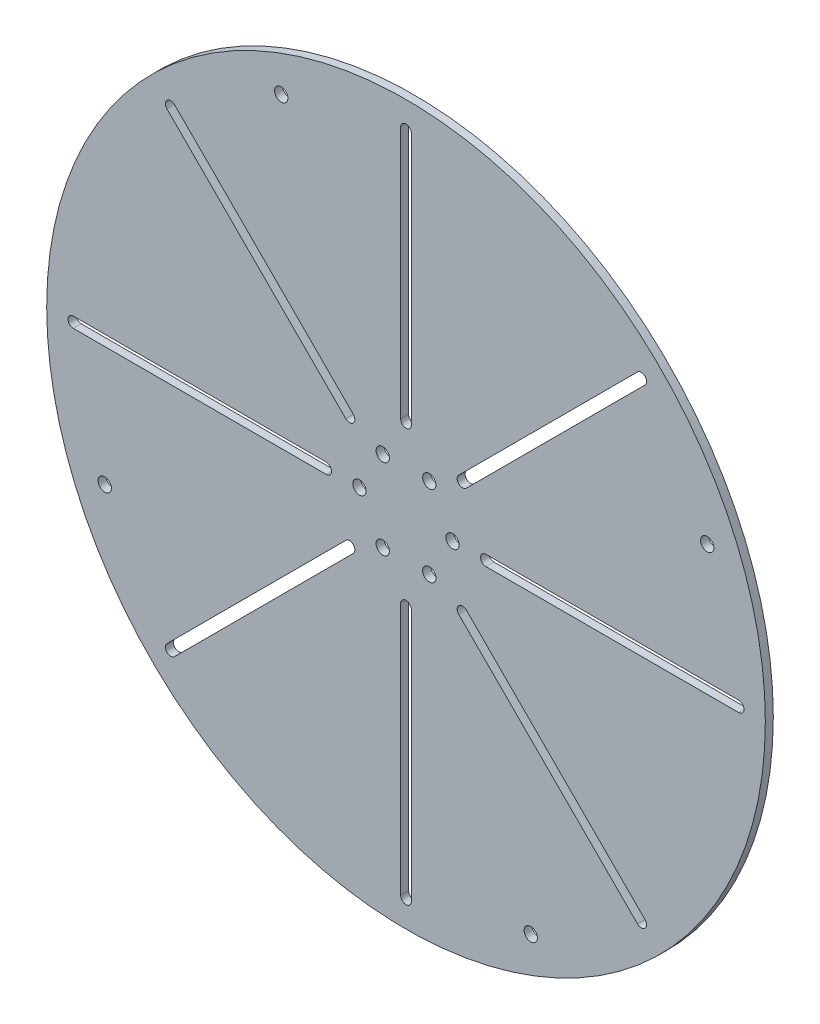
from build123d import *

# Parameters (mm, degrees)
SKETCH1_R           = 135
SKETCH1_R_2         = 2.5
BOSS_EXTRUDE1_DEPTH = 3


with BuildPart() as part:
    # Sketch1 → Boss-Extrude1 (new body)
    with BuildSketch(Plane.XY):
        Circle(SKETCH1_R)
        with Locations((-17.5, 0)):
            Circle(SKETCH1_R_2, mode=Mode.SUBTRACT)
        with Locations((-46.878720465, 113.175242733)):
            Circle(SKETCH1_R_2, mode=Mode.SUBTRACT)
        with Locations((113.175242733, 46.878720465)):
            Circle(SKETCH1_R_2, mode=Mode.SUBTRACT)
        with Locations((46.878720465, -113.175242733)):
            Circle(SKETCH1_R_2, mode=Mode.SUBTRACT)
        with Locations((-8.75, 15.155444566)):
            Circle(SKETCH1_R_2, mode=Mode.SUBTRACT)
        with Locations((8.75, 15.155444566)):
            Circle(SKETCH1_R_2, mode=Mode.SUBTRACT)
        with Locations((17.5, 0)):
            Circle(SKETCH1_R_2, mode=Mode.SUBTRACT)
        with Locations((8.75, -15.155444566)):
            Circle(SKETCH1_R_2, mode=Mode.SUBTRACT)
        with Locations((-8.75, -15.155444566)):
            Circle(SKETCH1_R_2, mode=Mode.SUBTRACT)
        with Locations((-113.175242733, -46.878720465)):
            Circle(SKETCH1_R_2, mode=Mode.SUBTRACT)
        with BuildLine():
            Line((30, 2), (125, 2))
            ThreePointArc((125, 2), (127, 0), (125, -2))
            Line((125, -2), (30, -2))
            ThreePointArc((30, -2), (28, 0), (30, 2))
        make_face(mode=Mode.SUBTRACT)
        with BuildLine():
            Line((22.627416998, -19.798989873), (89.802561211, -86.974134086))
            ThreePointArc((89.802561211, -86.974134086), (89.802561211, -89.802561211), (86.974134086, -89.802561211))
            Line((86.974134086, -89.802561211), (19.798989873, -22.627416998))
            ThreePointArc((19.798989873, -22.627416998), (19.798989873, -19.798989873), (22.627416998, -19.798989873))
        make_face(mode=Mode.SUBTRACT)
        with BuildLine():
            Line((2, -30), (2, -125))
            ThreePointArc((2, -125), (0, -127), (-2, -125))
            Line((-2, -125), (-2, -30))
            ThreePointArc((-2, -30), (0, -28), (2, -30))
        make_face(mode=Mode.SUBTRACT)
        with BuildLine():
            Line((-19.798989873, -22.627416998), (-86.974134086, -89.802561211))
            ThreePointArc((-86.974134086, -89.802561211), (-89.802561211, -89.802561211), (-89.802561211, -86.974134086))
            Line((-89.802561211, -86.974134086), (-22.627416998, -19.798989873))
            ThreePointArc((-22.627416998, -19.798989873), (-19.798989873, -19.798989873), (-19.798989873, -22.627416998))
        make_face(mode=Mode.SUBTRACT)
        with BuildLine():
            Line((-30, -2), (-125, -2))
            ThreePointArc((-125, -2), (-127, 0), (-125, 2))
            Line((-125, 2), (-30, 2))
            ThreePointArc((-30, 2), (-28, 0), (-30, -2))
        make_face(mode=Mode.SUBTRACT)
        with BuildLine():
            Line((-22.627416998, 19.798989873), (-89.802561211, 86.974134086))
            ThreePointArc((-89.802561211, 86.974134086), (-89.802561211, 89.802561211), (-86.974134086, 89.802561211))
            Line((-86.974134086, 89.802561211), (-19.798989873, 22.627416998))
            ThreePointArc((-19.798989873, 22.627416998), (-19.798989873, 19.798989873), (-22.627416998, 19.798989873))
        make_face(mode=Mode.SUBTRACT)
        with BuildLine():
            Line((-2, 30), (-2, 125))
            ThreePointArc((-2, 125), (0, 127), (2, 125))
            Line((2, 125), (2, 30))
            ThreePointArc((2, 30), (0, 28), (-2, 30))
        make_face(mode=Mode.SUBTRACT)
        with BuildLine():
            Line((19.798989873, 22.627416998), (86.974134086, 89.802561211))
            ThreePointArc((86.974134086, 89.802561211), (89.802561211, 89.802561211), (89.802561211, 86.974134086))
            Line((89.802561211, 86.974134086), (22.627416998, 19.798989873))
            ThreePointArc((22.627416998, 19.798989873), (19.798989873, 19.798989873), (19.798989873, 22.627416998))
        make_face(mode=Mode.SUBTRACT)
    extrude(amount=BOSS_EXTRUDE1_DEPTH)


solid = part.part
